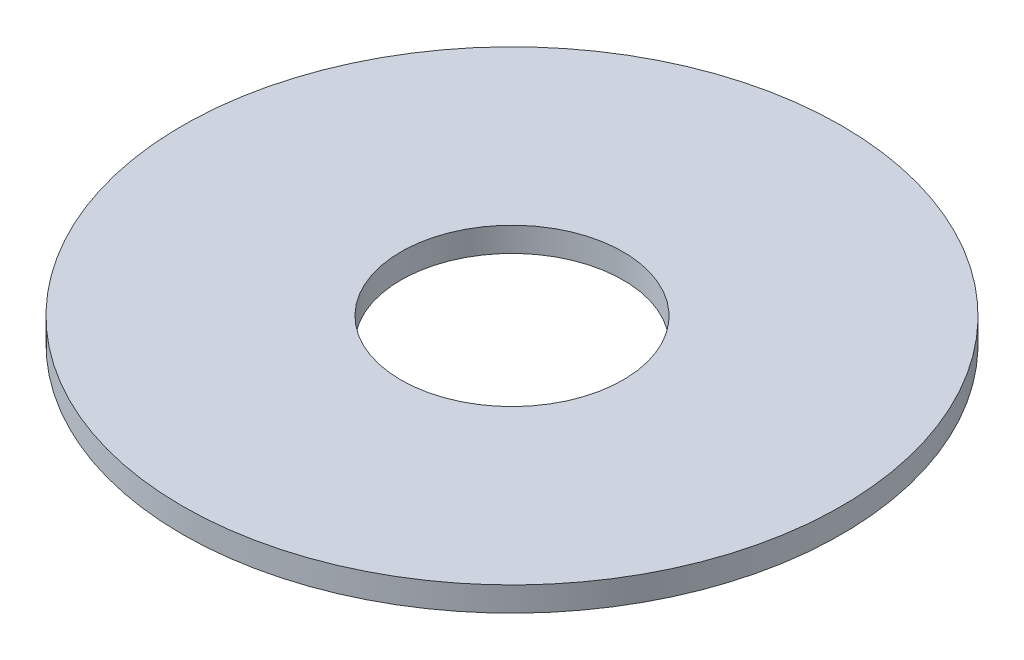
from build123d import *

# Parameters (mm, degrees)
SKETCH1_R           = 7.874
BOSS_EXTRUDE1_DEPTH = 0.5842
SKETCH5_R           = 2.6543
CUT_EXTRUDE1_DEPTH  = 1.5842


with BuildPart() as part:
    # Sketch1 → Boss-Extrude1 (new body)
    with BuildSketch(Plane(origin=(0, 0, 0), x_dir=(1, 0, 0), z_dir=(0, 1, 0))):
        Circle(SKETCH1_R)
    extrude(amount=BOSS_EXTRUDE1_DEPTH)

    # Sketch5 → Cut-Extrude1 (cut, through all)
    with BuildSketch(Plane(origin=(0, 0.5842, 0), x_dir=(-1, 0, 0), z_dir=(0, 1, 0))):
        Circle(SKETCH5_R)
    extrude(amount=-CUT_EXTRUDE1_DEPTH, mode=Mode.SUBTRACT)


solid = part.part
